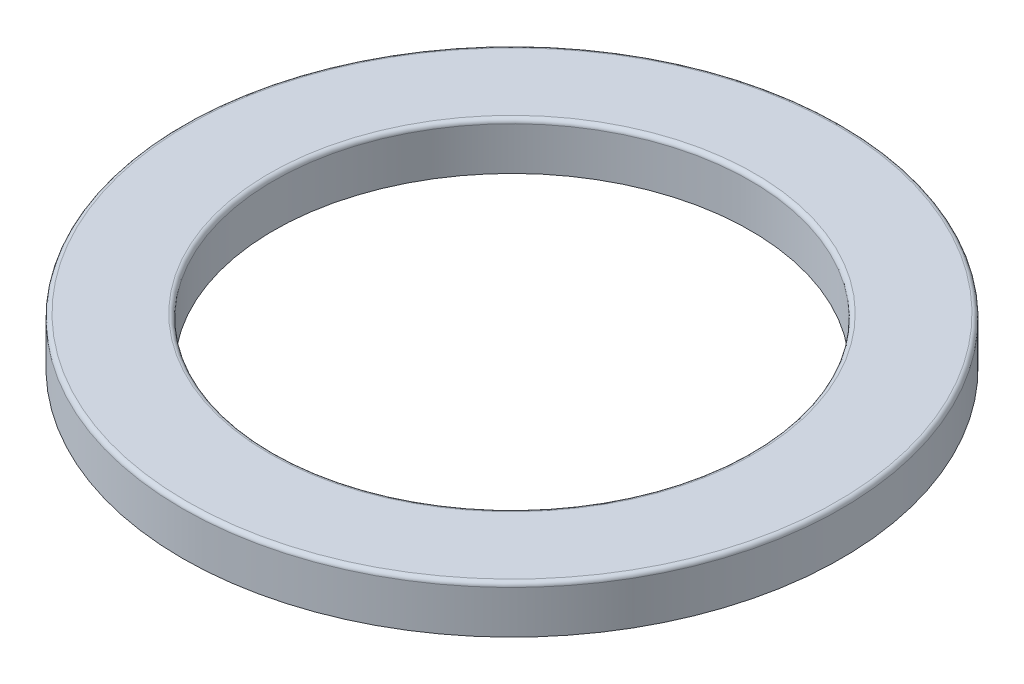
from build123d import *

# Parameters (mm, degrees)
SKETCH1_R           = 85
SKETCH1_R_2         = 61.5
BOSS_EXTRUDE1_DEPTH = 12.2
FILLET1_R           = 1.1


with BuildPart() as part:
    # Sketch1 → Boss-Extrude1 (new body)
    with BuildSketch(Plane(origin=(0, 0, 0), x_dir=(1, 0, 0), z_dir=(0, 1, 0))):
        Circle(SKETCH1_R)
        Circle(SKETCH1_R_2, mode=Mode.SUBTRACT)
    extrude(amount=BOSS_EXTRUDE1_DEPTH)

    # Fillet1
    fillet1_edges = [part.edges().sort_by_distance(p)[0] for p in [
        (-85, 12.2, 0),
        (-61.5, 12.2, 0),
    ]]
    fillet(fillet1_edges, radius=FILLET1_R)

    # Sketch2 → Cut-Revolve1 (revolve, cut)
    with BuildSketch(Plane.XY):
        with BuildLine():
            Line((-77.98, 0), (-67.02, 0))
            ThreePointArc((-67.02, 0), (-72.5, 1.827500428), (-77.98, 0))
        make_face()
    revolve(axis=Axis((0, 11.1, 0), (0, -1, 0)), mode=Mode.SUBTRACT)


solid = part.part
